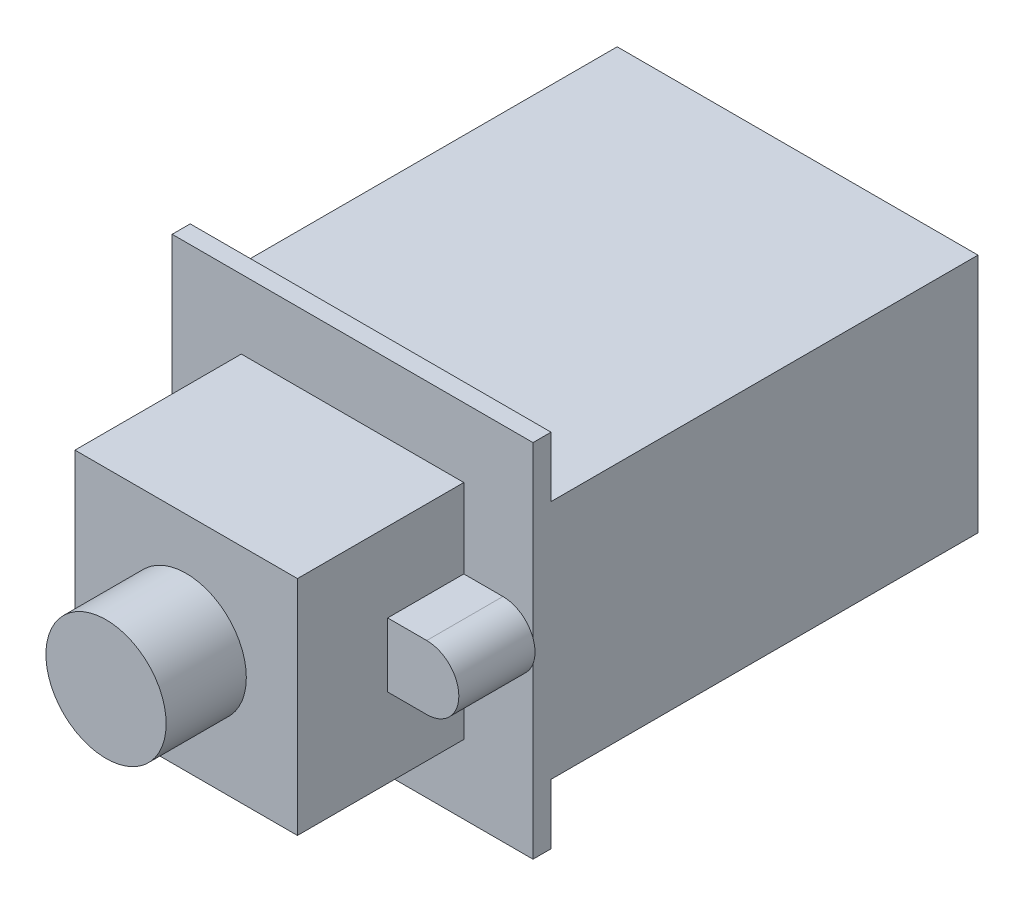
from build123d import *

# Parameters (mm, degrees)
SKETCH1_W           = 14.097
SKETCH1_H           = 14.097
BOSS_EXTRUDE1_DEPTH = 10.541
SKETCH2_R           = 3.81
BOSS_EXTRUDE2_DEPTH = 5.08
BOSS_EXTRUDE3_DEPTH = 4.826
SKETCH4_W           = 22.86
SKETCH4_H           = 22.86
BOSS_EXTRUDE4_DEPTH = 1.143
SKETCH5_W           = 22.86
SKETCH5_H           = 15.24
BOSS_EXTRUDE5_DEPTH = 27.051


with BuildPart() as part:
    # Sketch1 → Boss-Extrude1 (new body)
    with BuildSketch(Plane.XY):
        Rectangle(SKETCH1_W, SKETCH1_H)
    extrude(amount=BOSS_EXTRUDE1_DEPTH)

    # Sketch2 → Boss-Extrude2 (add)
    with BuildSketch(Plane.XY.offset(10.541)):
        Circle(SKETCH2_R)
    extrude(amount=BOSS_EXTRUDE2_DEPTH)

    # Sketch3 → Boss-Extrude3 (add)
    with BuildSketch(Plane(origin=(0, 0, 0), x_dir=(-1, 0, 0), z_dir=(0, 0, -1))):
        with BuildLine():
            Line((-9.525, 2.032), (-7.0485, 2.032))
            Line((-7.0485, 2.032), (-7.0485, -2.032))
            Line((-7.0485, -2.032), (-9.525, -2.032))
            ThreePointArc((-9.525, -2.032), (-11.557, 0), (-9.525, 2.032))
        make_face()
    boss_extrude3 = extrude(amount=-BOSS_EXTRUDE3_DEPTH)

    # Mirror1: Boss-Extrude3 across plane
    add(boss_extrude3.mirror(Plane(origin=(0, 0, 0), x_dir=(0, 0, 1), z_dir=(1, 0, 0))))

    # Sketch4 → Boss-Extrude4 (add)
    with BuildSketch(Plane(origin=(0, 0, 0), x_dir=(-1, 0, 0), z_dir=(0, 0, -1))):
        Rectangle(SKETCH4_W, SKETCH4_H)
    extrude(amount=BOSS_EXTRUDE4_DEPTH)

    # Sketch5 → Boss-Extrude5 (add)
    with BuildSketch(Plane(origin=(0, 0, -1.143), x_dir=(-1, 0, 0), z_dir=(0, 0, -1))):
        Rectangle(SKETCH5_W, SKETCH5_H)
    extrude(amount=BOSS_EXTRUDE5_DEPTH)


solid = part.part
